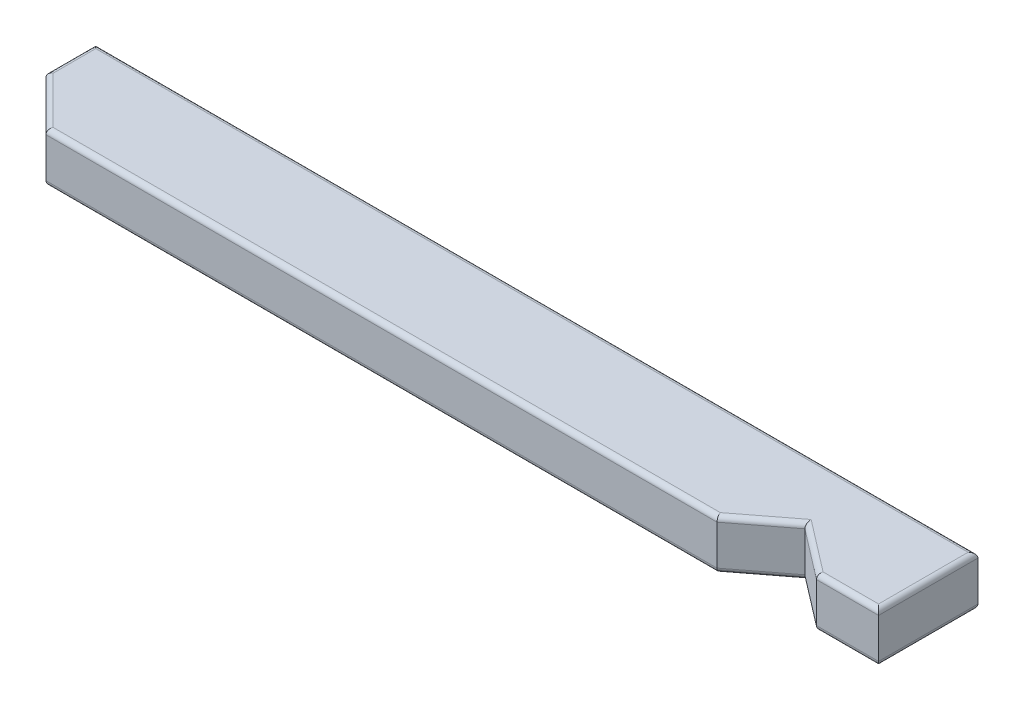
from build123d import *

# Parameters (mm, degrees)
SKETCH1_W           = 901.6
SKETCH1_H           = 101.6
BOSS_EXTRUDE1_DEPTH = 50.8
CUT_EXTRUDE1_DEPTH  = 51.8
FILLET1_R           = 5.08


with BuildPart() as part:
    # Sketch1 → Boss-Extrude1 (new body)
    with BuildSketch(Plane(origin=(0, -12.7, 0), x_dir=(-1, 0, 0), z_dir=(0, -1, 0))):
        with Locations((-2263.5, 338.5)):
            Rectangle(SKETCH1_W, SKETCH1_H)
    extrude(amount=-BOSS_EXTRUDE1_DEPTH)

    # Sketch3 → Cut-Extrude1 (cut, through all)
    with BuildSketch(Plane(origin=(0, 38.1, 0), x_dir=(1, 0, 0), z_dir=(0, 1, 0))):
        Polygon((2549.2, 287.7), (2600, 326.680210989), (2650.8, 287.7), align=None)
        Polygon((1812.7, 338.5), (1812.7, 287.7), (1863.5, 287.7), align=None)
    extrude(amount=-CUT_EXTRUDE1_DEPTH, mode=Mode.SUBTRACT)

    # Fillet1
    fillet1_edges = [part.edges().sort_by_distance(p)[0] for p in [
        (2206.35, -12.7, -287.7),
        (1812.7, -12.7, -363.9),
        (2263.5, 38.1, -389.3),
        (1812.7, 38.1, -363.9),
        (2206.35, 38.1, -287.7),
        (2574.6, -12.7, -307.190105495),
        (2625.4, -12.7, -307.190105495),
        (2625.4, 38.1, -307.190105495),
        (2574.6, 38.1, -307.190105495),
        (1838.1, -12.7, -313.1),
        (1838.1, 38.1, -313.1),
        (2714.3, 38.1, -338.5),
        (2263.5, -12.7, -389.3),
        (2682.55, -12.7, -287.7),
        (2714.3, -12.7, -338.5),
        (2682.55, 38.1, -287.7),
    ]]
    fillet(fillet1_edges, radius=FILLET1_R)


solid = part.part
